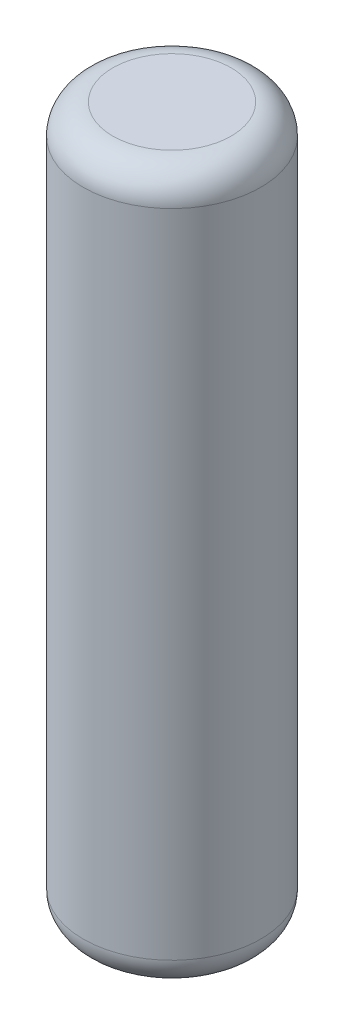
from build123d import *

# Parameters (mm, degrees)
SKETCH1_R           = 30
BOSS_EXTRUDE1_DEPTH = 240
FILLET1_R           = 10


with BuildPart() as part:
    # Sketch1 → Boss-Extrude1 (new body)
    with BuildSketch(Plane(origin=(0, 0, 0), x_dir=(1, 0, 0), z_dir=(0, 1, 0))):
        Circle(SKETCH1_R)
    extrude(amount=BOSS_EXTRUDE1_DEPTH)

    # Fillet1
    fillet1_edges = [part.edges().sort_by_distance(p)[0] for p in [
        (-30, 0, 0),
        (-30, 240, 0),
    ]]
    fillet(fillet1_edges, radius=FILLET1_R)


solid = part.part
